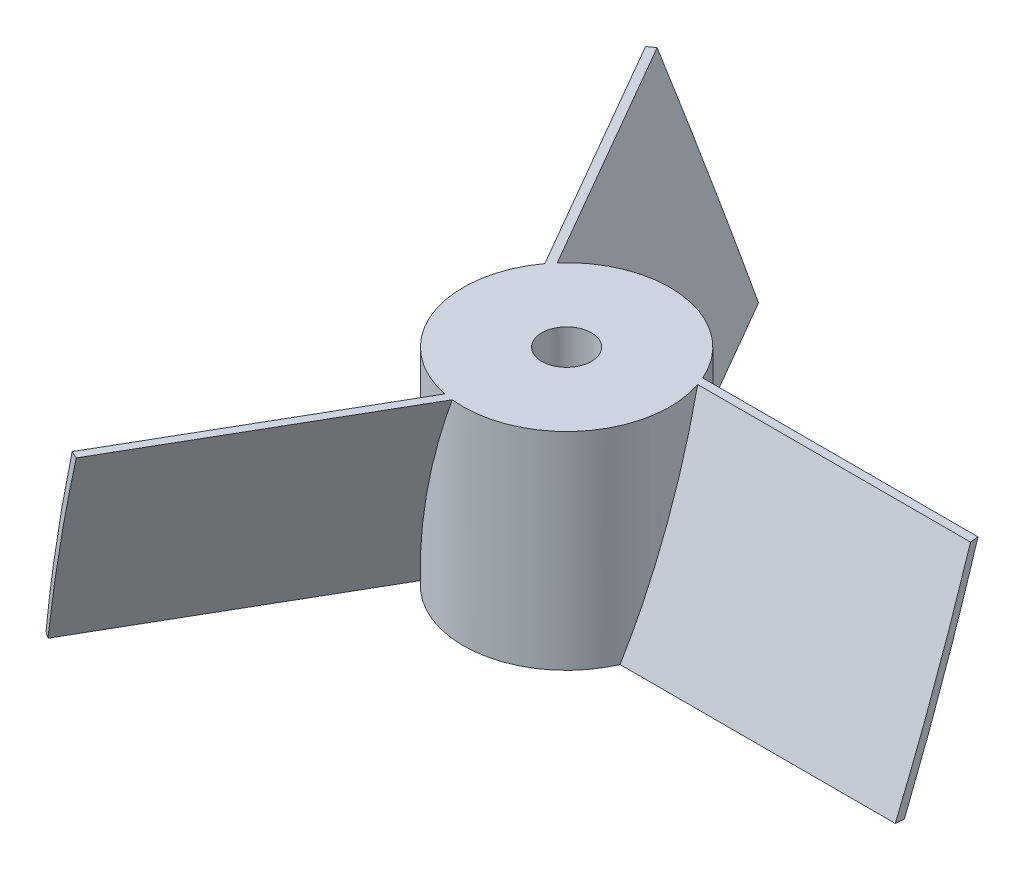
from build123d import *

# Parameters (mm, degrees)
SKETCH2_R           = 25
BOSS_EXTRUDE1_DEPTH = 50
BOSS_EXTRUDE2_DEPTH = 100
CIRPATTERN1_COUNT   = 3
SKETCH5_R           = 150
SKETCH5_R_2         = 90
CUT_EXTRUDE3_DEPTH  = 51
SKETCH3_R           = 6
CUT_EXTRUDE1_DEPTH  = 51


with BuildPart() as part:
    # Sketch2 → Boss-Extrude1 (new body)
    with BuildSketch(Plane(origin=(0, 0, 0), x_dir=(1, 0, 0), z_dir=(0, 1, 0))):
        Circle(SKETCH2_R)
    extrude(amount=BOSS_EXTRUDE1_DEPTH)

    # Sketch4 → Boss-Extrude2 (add)
    with BuildSketch(Plane(origin=(0, 0, 0), x_dir=(0, 0, -1), z_dir=(1, 0, 0))):
        Polygon((10, 50), (8, 50), (-10, 0), (-8, 0), align=None)
    boss_extrude2 = extrude(amount=BOSS_EXTRUDE2_DEPTH)

    # CirPattern1: Boss-Extrude2 ×3 about axis
    cirpattern1_axis = Axis((0, 0, 0), (0, 1, 0))
    for i in range(1, CIRPATTERN1_COUNT):
        add(boss_extrude2.rotate(cirpattern1_axis, i * 360 / CIRPATTERN1_COUNT))

    # Sketch5 → Cut-Extrude3 (cut, through all)
    with BuildSketch(Plane(origin=(0, 50, 0), x_dir=(1, 0, 0), z_dir=(0, 1, 0))):
        Circle(SKETCH5_R)
        Circle(SKETCH5_R_2, mode=Mode.SUBTRACT)
    extrude(amount=-CUT_EXTRUDE3_DEPTH, mode=Mode.SUBTRACT)

    # Sketch3 → Cut-Extrude1 (cut, through all)
    with BuildSketch(Plane(origin=(0, 50, 0), x_dir=(1, 0, 0), z_dir=(0, 1, 0))):
        Circle(SKETCH3_R)
    extrude(amount=-CUT_EXTRUDE1_DEPTH, mode=Mode.SUBTRACT)


solid = part.part
